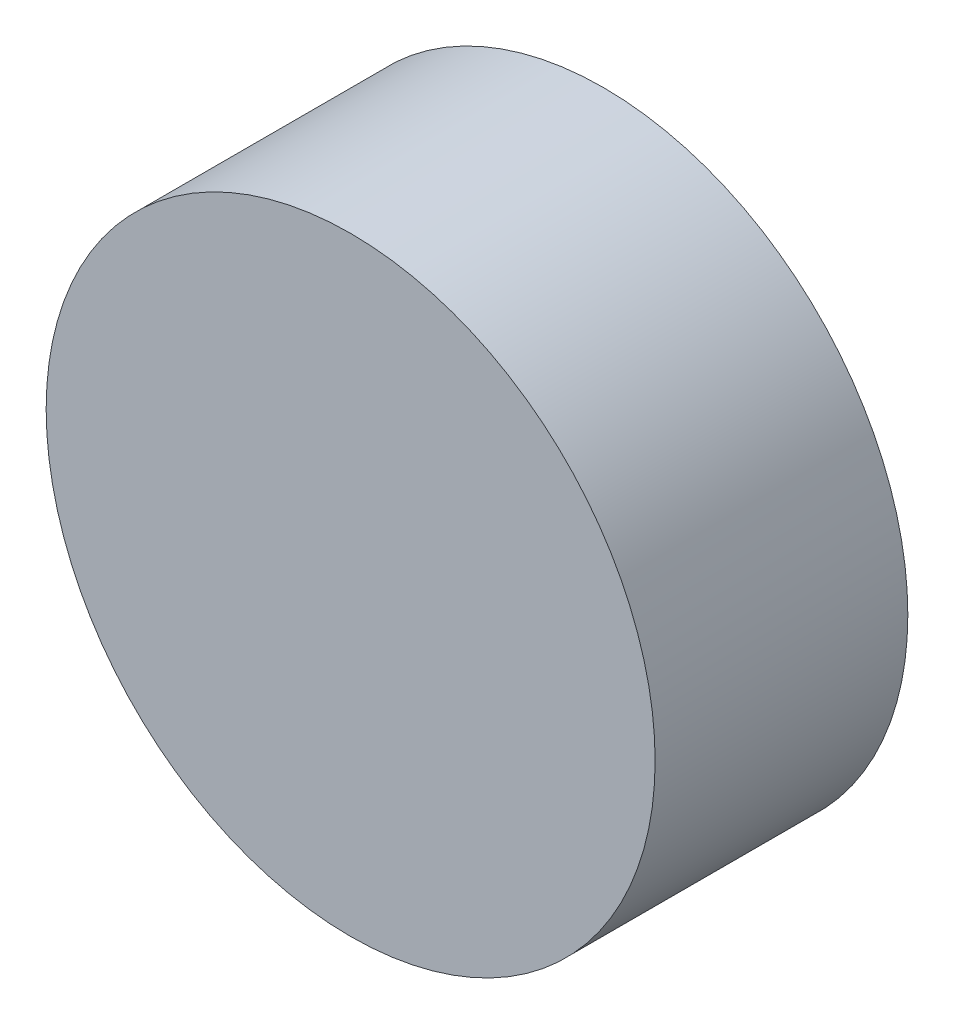
from build123d import *

# Parameters (mm, degrees)
SKETCH1_R           = 234.95
BOSS_EXTRUDE1_DEPTH = 195


with BuildPart() as part:
    # Sketch1 → Boss-Extrude1 (new body)
    with BuildSketch(Plane.XY):
        Circle(SKETCH1_R)
    extrude(amount=-BOSS_EXTRUDE1_DEPTH)


solid = part.part
